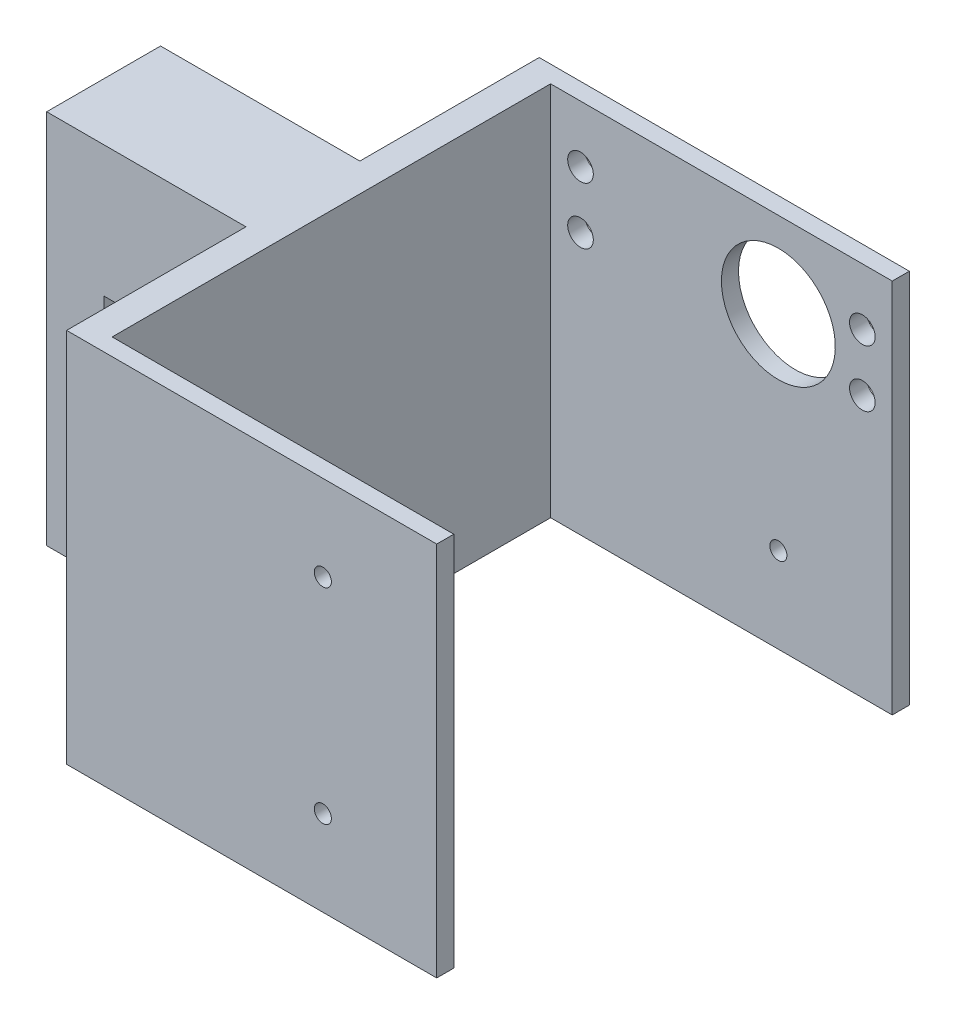
from build123d import *

# Parameters (mm, degrees)
SKETCH_3_R               = 3
EXTRUDE_6_DEPTH          = 0.001
EXTRUDE_6_2_DEPTH        = 0.001
EXTRUDE_6_3_DEPTH        = 0.001
EXTRUDE_6_4_DEPTH        = 0.001
CUT_EXTRUDE_2_DEPTH      = 67.213034483
CUT_EXTRUDE_2_DEPTH_BACK = 67.213034483
SKETCH_11_R              = 2.25
EXTRUDE_7_DEPTH          = 3
CUT_EXTRUDE_START        = -3
SKETCH_14_R              = 2.25
SKETCH_14_R_2            = 10
CUT_EXTRUDE_3_DEPTH      = 3
SKETCH_15_R              = 10
SKETCH_15_R_2            = 1.5
CUT_EXTRUDE_4_DEPTH      = 65
SKETCH_17_R              = 7.5
SKETCH_17_R_2            = 5.5
EXTRUDE_8_DEPTH          = 7
SKETCH_12_4_R            = 10
EXTRUDE_10_DEPTH         = 83
SKETCH_20_W              = 77
SKETCH_20_H              = 66
CUT_EXTRUDE_6_DEPTH      = 60
SKETCH_21_W              = 83
SKETCH_21_H              = 66
EXTRUDE_11_DEPTH         = 40
CUT_EXTRUDE_START_2      = -40
SKETCH_14_3_R            = 2.25
SKETCH_14_3_R_2          = 10
CUT_EXTRUDE_7_DEPTH      = 40
SKETCH_23_R              = 10
EXTRUDE_12_DEPTH         = 3
CUT_EXTRUDE_9_DEPTH      = 100
CUT_EXTRUDE_9_DEPTH_BACK = 100
SKETCH_22_R              = 1.5
SKETCH_25_W              = 20
SKETCH_25_H              = 20
CUT_EXTRUDE_10_DEPTH     = 100
SKETCH_28_W              = 35
SKETCH_28_H              = 31.5
CUT_EXTRUDE_12_DEPTH     = 125.649809312


with BuildPart() as part:
    # 草图3 → 凸台-拉伸6 (new body)
    with BuildSketch(Plane.XY):
        with Locations((60.266478541, 16.532501821)):
            Circle(SKETCH_3_R)
    extrude(amount=EXTRUDE_6_DEPTH)


with BuildPart() as body_2:
    # 草图3 → Extrude 6 2 (new body)
    with BuildSketch(Plane.XY):
        with Locations((60.266478541, 6.532501821)):
            Circle(SKETCH_3_R)
    extrude(amount=EXTRUDE_6_2_DEPTH)


with BuildPart() as body_3:
    # 草图3 → Extrude 6 3 (new body)
    with BuildSketch(Plane.XY):
        with Locations((10.766478541, 6.532501821)):
            Circle(SKETCH_3_R)
    extrude(amount=EXTRUDE_6_3_DEPTH)


with BuildPart() as body_4:
    # 草图3 → Extrude 6 4 (new body)
    with BuildSketch(Plane.XY):
        with Locations((10.766478541, 16.532501821)):
            Circle(SKETCH_3_R)
    extrude(amount=EXTRUDE_6_4_DEPTH)


with BuildPart() as cut_extrude_2_tool:
    # 草图11 → 切除-拉伸2 (new, two sides: drawn at the far end of the back side and taken through both)
    with BuildSketch(Plane.XY.offset(0.001).offset(-CUT_EXTRUDE_2_DEPTH_BACK)):
        with Locations((10.766478541, 16.532501821)):
            Circle(SKETCH_11_R)
        with Locations((10.766478541, 6.532501821)):
            Circle(SKETCH_11_R)
        with Locations((60.266478541, 16.532501821)):
            Circle(SKETCH_11_R)
        with Locations((60.266478541, 6.532501821)):
            Circle(SKETCH_11_R)
    extrude(amount=CUT_EXTRUDE_2_DEPTH + CUT_EXTRUDE_2_DEPTH_BACK)


with BuildPart() as part_1:
    add(part.part)

    # 切除-拉伸2: cut by cut_extrude_2_tool
    add(cut_extrude_2_tool.part, mode=Mode.SUBTRACT)


with BuildPart() as body_2_1:
    add(body_2.part)

    # 切除-拉伸2: cut by cut_extrude_2_tool
    add(cut_extrude_2_tool.part, mode=Mode.SUBTRACT)


with BuildPart() as body_3_1:
    add(body_3.part)

    # 切除-拉伸2: cut by cut_extrude_2_tool
    add(cut_extrude_2_tool.part, mode=Mode.SUBTRACT)


with BuildPart() as body_4_1:
    add(body_4.part)

    # 切除-拉伸2: cut by cut_extrude_2_tool
    add(cut_extrude_2_tool.part, mode=Mode.SUBTRACT)


with BuildPart() as body_5:
    # 草图12 → 凸台-拉伸7 (new body)
    with BuildSketch(Plane.XY.offset(0.001)):
        Polygon((5.516478541, 26.532501821), (65.516478541, 26.532501821), (65.516478541, -39.467498179), (5.516478541, -39.467498179), (5.516478541, 1.532501821), align=None)
    extrude(amount=EXTRUDE_7_DEPTH)

    # 草图14 → 切除-拉伸3 (cut)
    with BuildSketch(Plane(origin=(0, 0, 0.001), x_dir=(-1, 0, 0), z_dir=(0, 0, -1)).offset(CUT_EXTRUDE_START)):
        with Locations((-60.266478541, 6.532501821)):
            Circle(SKETCH_14_R)
        with Locations((-60.266478541, 16.532501821)):
            Circle(SKETCH_14_R)
        with Locations((-10.766478541, 6.532501821)):
            Circle(SKETCH_14_R)
        with Locations((-10.766478541, 16.532501821)):
            Circle(SKETCH_14_R)
        with Locations((-45.516478541, 11.532501821)):
            Circle(SKETCH_14_R_2)
    extrude(amount=CUT_EXTRUDE_3_DEPTH, mode=Mode.SUBTRACT)

    # 草图15 → 切除-拉伸4 (cut)
    with BuildSketch(Plane(origin=(0, 0, 0.001), x_dir=(-1, 0, 0), z_dir=(0, 0, -1))):
        with Locations((-45.516478541, 11.532501821)):
            Circle(SKETCH_15_R)
        with Locations((-45.516478541, -24.467498179)):
            Circle(SKETCH_15_R_2)
    extrude(amount=-CUT_EXTRUDE_4_DEPTH, mode=Mode.SUBTRACT)

    # 草图17 → 凸台-拉伸8 (add)
    with BuildSketch(Plane.XY.offset(3.001)):
        with Locations((45.516478541, -24.467498179)):
            Circle(SKETCH_17_R)
        with Locations((45.516478541, -24.467498179)):
            Circle(SKETCH_17_R_2, mode=Mode.SUBTRACT)
    extrude(amount=-EXTRUDE_8_DEPTH)

    # 草图12<4> → 凸台-拉伸10 (add)
    with BuildSketch(Plane.XY.offset(0.001)):
        Polygon((5.516478541, 26.532501821), (65.516478541, 26.532501821), (65.516478541, -39.467498179), (5.516478541, -39.467498179), (5.516478541, 1.532501821), align=None)
        with Locations((45.516478541, 11.532501821)):
            Circle(SKETCH_12_4_R, mode=Mode.SUBTRACT)
    extrude(amount=EXTRUDE_10_DEPTH)

    # 草图20 → 切除-拉伸6 (cut)
    with BuildSketch(Plane(origin=(65.516478541, 0, 0), x_dir=(0, 0, -1), z_dir=(1, 0, 0))):
        with Locations((-41.501, -6.467498179)):
            Rectangle(SKETCH_20_W, SKETCH_20_H)
    extrude(amount=-CUT_EXTRUDE_6_DEPTH, mode=Mode.SUBTRACT)


with BuildPart() as cut_extrude_6_piece_1:
    # of the separate pieces the step leaves, piece 1, a body of its own (cut_extrude_6_pieces)
    add(body_5.part.solids().sort_by_distance((5.516478541, 26.532501821, 0.001))[0])



with BuildPart() as cut_extrude_6_piece_2:
    # of the separate pieces the step leaves, piece 2, a body of its own (cut_extrude_6_pieces)
    add(body_5.part.solids().sort_by_distance((65.516478541, 26.532501821, 80.001))[0])


with BuildPart() as cut_extrude_6_piece_1_1:
    add(cut_extrude_6_piece_1.part)

    add(cut_extrude_6_piece_2.part)  # 凸台-拉伸11 merges 切除-拉伸6 piece 2
    # 草图21 → 凸台-拉伸11 (add)
    with BuildSketch(Plane.ZY.offset(-5.516478541)):
        with Locations((41.501, -6.467498179)):
            Rectangle(SKETCH_21_W, SKETCH_21_H)
    extrude(amount=EXTRUDE_11_DEPTH)

    # 草图14<3> → 切除-拉伸7 (cut)
    with BuildSketch(Plane(origin=(0, 0, 0.001), x_dir=(-1, 0, 0), z_dir=(0, 0, -1)).offset(CUT_EXTRUDE_START_2)):
        with Locations((-60.266478541, 6.532501821)):
            Circle(SKETCH_14_3_R)
        with Locations((-60.266478541, 16.532501821)):
            Circle(SKETCH_14_3_R)
        with Locations((-10.766478541, 6.532501821)):
            Circle(SKETCH_14_3_R)
        with Locations((-10.766478541, 16.532501821)):
            Circle(SKETCH_14_3_R)
        with Locations((-45.516478541, 11.532501821)):
            Circle(SKETCH_14_3_R_2)
    extrude(amount=CUT_EXTRUDE_7_DEPTH, mode=Mode.SUBTRACT)

    # 草图23 → 凸台-拉伸12 (add)
    with BuildSketch(Plane.XY.offset(83.001)):
        with Locations((45.516478541, 11.532501821)):
            Circle(SKETCH_23_R)
    extrude(amount=-EXTRUDE_12_DEPTH)

    # 草图22 → 切除-拉伸9 (cut, two sides: drawn at the far end of the back side and taken through both)
    with BuildSketch(Plane.XY.offset(3.001).offset(-CUT_EXTRUDE_9_DEPTH_BACK)):
        with Locations((45.516478541, 11.532501821)):
            Circle(SKETCH_22_R)
        with Locations((45.516478541, -24.467498179)):
            Circle(SKETCH_22_R)
    extrude(amount=CUT_EXTRUDE_9_DEPTH + CUT_EXTRUDE_9_DEPTH_BACK, mode=Mode.SUBTRACT)

    # 草图25 → 切除-拉伸10 (cut)
    with BuildSketch(Plane(origin=(0, 0, 0.001), x_dir=(-1, 0, 0), z_dir=(0, 0, -1))):
        with Locations((14.433410721, -6.467498179)):
            Rectangle(SKETCH_25_W, SKETCH_25_H)
    extrude(amount=-CUT_EXTRUDE_10_DEPTH, mode=Mode.SUBTRACT)

    # 草图28 → 切除-拉伸12 (cut, through all)
    with BuildSketch(Plane.XZ.offset(39.467498179)):
        with Locations((-16.983521459, 15.751)):
            Rectangle(SKETCH_28_W, SKETCH_28_H)
        with Locations((-16.983521459, 67.251)):
            Rectangle(SKETCH_28_W, SKETCH_28_H)
    extrude(amount=-CUT_EXTRUDE_12_DEPTH, mode=Mode.SUBTRACT)


solid = Compound([part_1.part, body_2_1.part, body_3_1.part, body_4_1.part, cut_extrude_6_piece_1_1.part])
